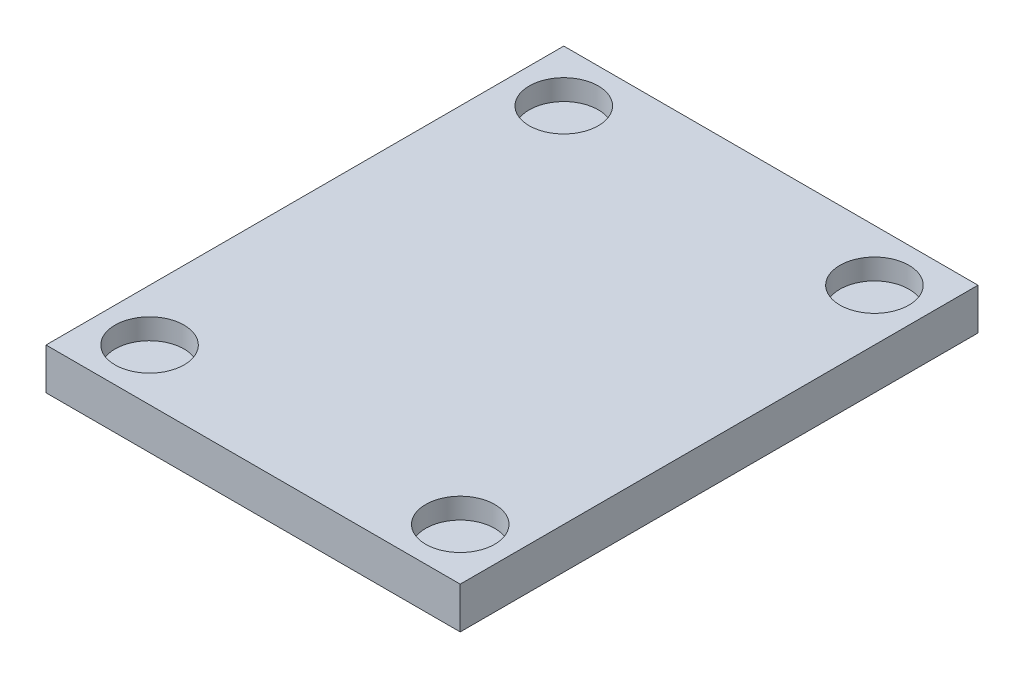
from build123d import *

# Parameters (mm, degrees)
SKETCH1_W           = 60
SKETCH1_H           = 6
BOSS_EXTRUDE1_DEPTH = 75
SKETCH3_R           = 5
CUT_EXTRUDE2_DEPTH  = 3


with BuildPart() as part:
    # Sketch1 → Boss-Extrude1 (new body)
    with BuildSketch(Plane.XY):
        Rectangle(SKETCH1_W, SKETCH1_H)
    extrude(amount=BOSS_EXTRUDE1_DEPTH)

    # Sketch3 → Cut-Extrude2 (cut)
    with BuildSketch(Plane(origin=(0, 3, 0), x_dir=(1, 0, 0), z_dir=(0, 1, 0))):
        with Locations((22.5, -67.5)):
            Circle(SKETCH3_R)
        with Locations((-22.5, -67.5)):
            Circle(SKETCH3_R)
        with Locations((-22.5, -7.5)):
            Circle(SKETCH3_R)
        with Locations((22.5, -7.5)):
            Circle(SKETCH3_R)
    extrude(amount=-CUT_EXTRUDE2_DEPTH, mode=Mode.SUBTRACT)


solid = part.part
